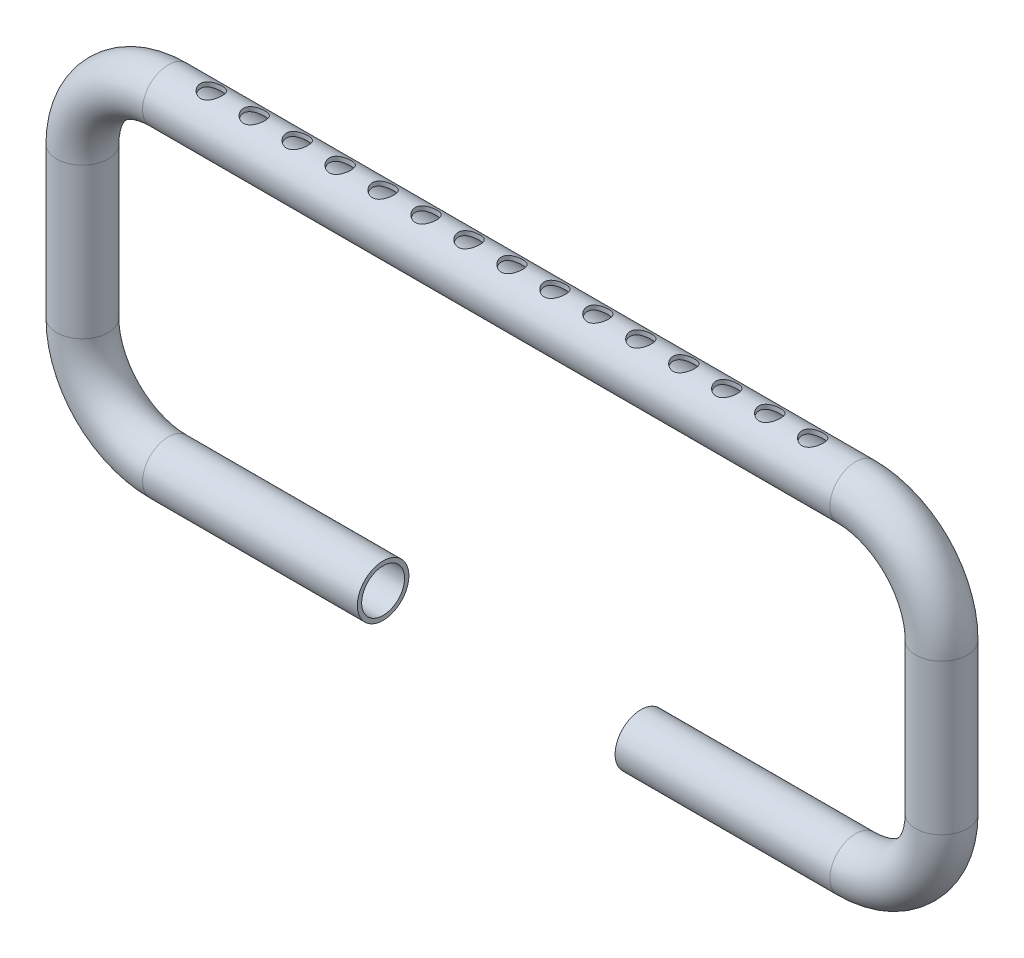
from build123d import *

# Parameters (mm, degrees)
SKETCH2_R          = 6
SKETCH2_R_2        = 5
SKETCH4_R          = 2.5
CUT_EXTRUDE1_DEPTH = 20


with BuildPart() as part:
    # Sweep1: sweep along a path in Sketch1
    with BuildLine(Plane.XY) as sweep1_path:
        Line((0, 0), (50, 0))
        ThreePointArc((50, 0), (64.142135624, 5.857864376), (70, 20))
        Line((70, 20), (70, 55))
        ThreePointArc((70, 55), (64.142135624, 69.142135624), (50, 75))
        Line((50, 75), (-110, 75))
        ThreePointArc((-110, 75), (-124.142135624, 69.142135624), (-130, 55))
        Line((-130, 55), (-130, 20))
        ThreePointArc((-130, 20), (-124.142135624, 5.857864376), (-110, 0))
        Line((-110, 0), (-60, 0))
    # Sketch2 → Sweep1 (sweep)
    with BuildSketch(Plane(origin=(0, 0, 0), x_dir=(0, 0, -1), z_dir=(1, 0, 0))):
        Circle(SKETCH2_R)
        Circle(SKETCH2_R_2, mode=Mode.SUBTRACT)
    sweep(path=sweep1_path.line)

    # Sketch4 → Cut-Extrude1 (cut)
    with BuildSketch(Plane(origin=(0, 81, 0), x_dir=(1, 0, 0), z_dir=(0, 1, 0))):
        with Locations((-100, 0)):
            Circle(SKETCH4_R)
        with Locations((-90, 0)):
            Circle(SKETCH4_R)
        with Locations((-80, 0)):
            Circle(SKETCH4_R)
        with Locations((-70, 0)):
            Circle(SKETCH4_R)
        with Locations((-60, 0)):
            Circle(SKETCH4_R)
        with Locations((-50, 0)):
            Circle(SKETCH4_R)
        with Locations((-40, 0)):
            Circle(SKETCH4_R)
        with Locations((-30, 0)):
            Circle(SKETCH4_R)
        with Locations((-20, 0)):
            Circle(SKETCH4_R)
        with Locations((-10, 0)):
            Circle(SKETCH4_R)
        Circle(SKETCH4_R)
        with Locations((10, 0)):
            Circle(SKETCH4_R)
        with Locations((20, 0)):
            Circle(SKETCH4_R)
        with Locations((30, 0)):
            Circle(SKETCH4_R)
        with Locations((40, 0)):
            Circle(SKETCH4_R)
    extrude(amount=-CUT_EXTRUDE1_DEPTH, mode=Mode.SUBTRACT)


solid = part.part
